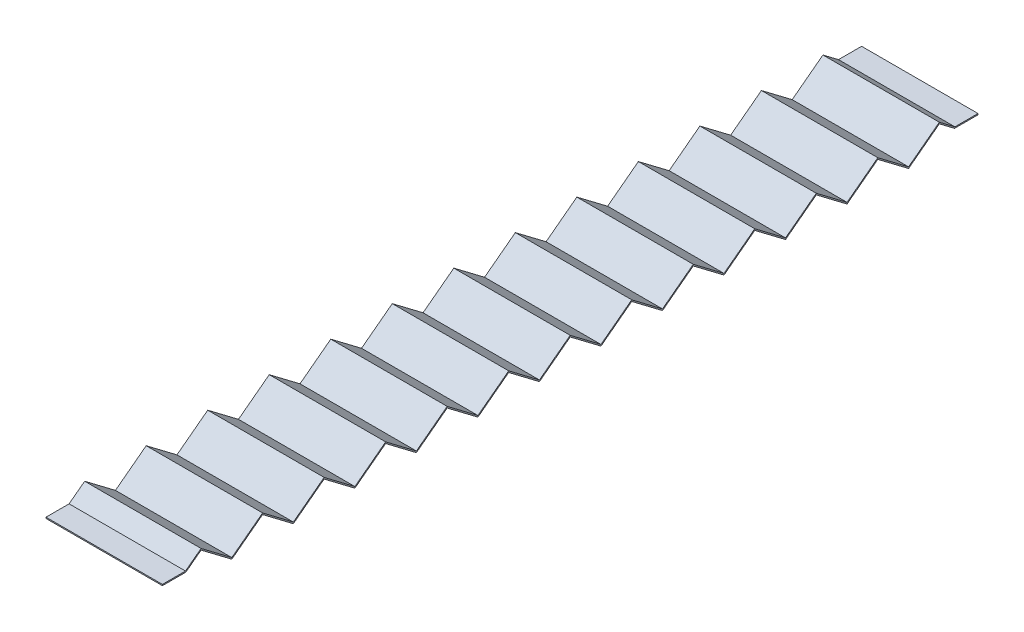
from build123d import *

# Parameters (mm, degrees)
EXTRUDE_THIN1_DEPTH = 25


with BuildPart() as part:
    # Sketch3 → Extrude-Thin1 (new body, symmetric)
    with BuildSketch(Plane(origin=(0, 0, 0), x_dir=(0, 0, -1), z_dir=(1, 0, 0))):
        Polygon((0, 4.75), (10.083940671, 4.75), (16.606328425, 9.686469499), (29.818985275, -0.313530501), (43.031642125, 9.686469499), (56.244298974, -0.313530501), (69.456955824, 9.686469499), (82.669612674, -0.313530501), (95.882269524, 9.686469499), (109.094926374, -0.313530501), (122.307583223, 9.686469499), (135.520240073, -0.313530501), (148.732896923, 9.686469499), (161.945553773, -0.313530501), (175.158210623, 9.686469499), (188.370867472, -0.313530501), (201.583524322, 9.686469499), (214.796181172, -0.313530501), (228.008838022, 9.686469499), (241.221494872, -0.313530501), (254.434151721, 9.686469499), (267.646808571, -0.313530501), (280.859465421, 9.686469499), (294.072122271, -0.313530501), (307.284779121, 9.686469499), (320.49743597, -0.313530501), (333.71009282, 9.686469499), (340.232480575, 4.75), (350.316421245, 4.75), (350.316421245, 5.25), (340.400361916, 5.25), (333.71009282, 10.313530501), (320.49743597, 0.313530501), (307.284779121, 10.313530501), (294.072122271, 0.313530501), (280.859465421, 10.313530501), (267.646808571, 0.313530501), (254.434151721, 10.313530501), (241.221494872, 0.313530501), (228.008838022, 10.313530501), (214.796181172, 0.313530501), (201.583524322, 10.313530501), (188.370867472, 0.313530501), (175.158210623, 10.313530501), (161.945553773, 0.313530501), (148.732896923, 10.313530501), (135.520240073, 0.313530501), (122.307583223, 10.313530501), (109.094926374, 0.313530501), (95.882269524, 10.313530501), (82.669612674, 0.313530501), (69.456955824, 10.313530501), (56.244298974, 0.313530501), (43.031642125, 10.313530501), (29.818985275, 0.313530501), (16.606328425, 10.313530501), (9.916059329, 5.25), (0, 5.25), align=None)
    extrude(amount=EXTRUDE_THIN1_DEPTH, both=True)


solid = part.part
